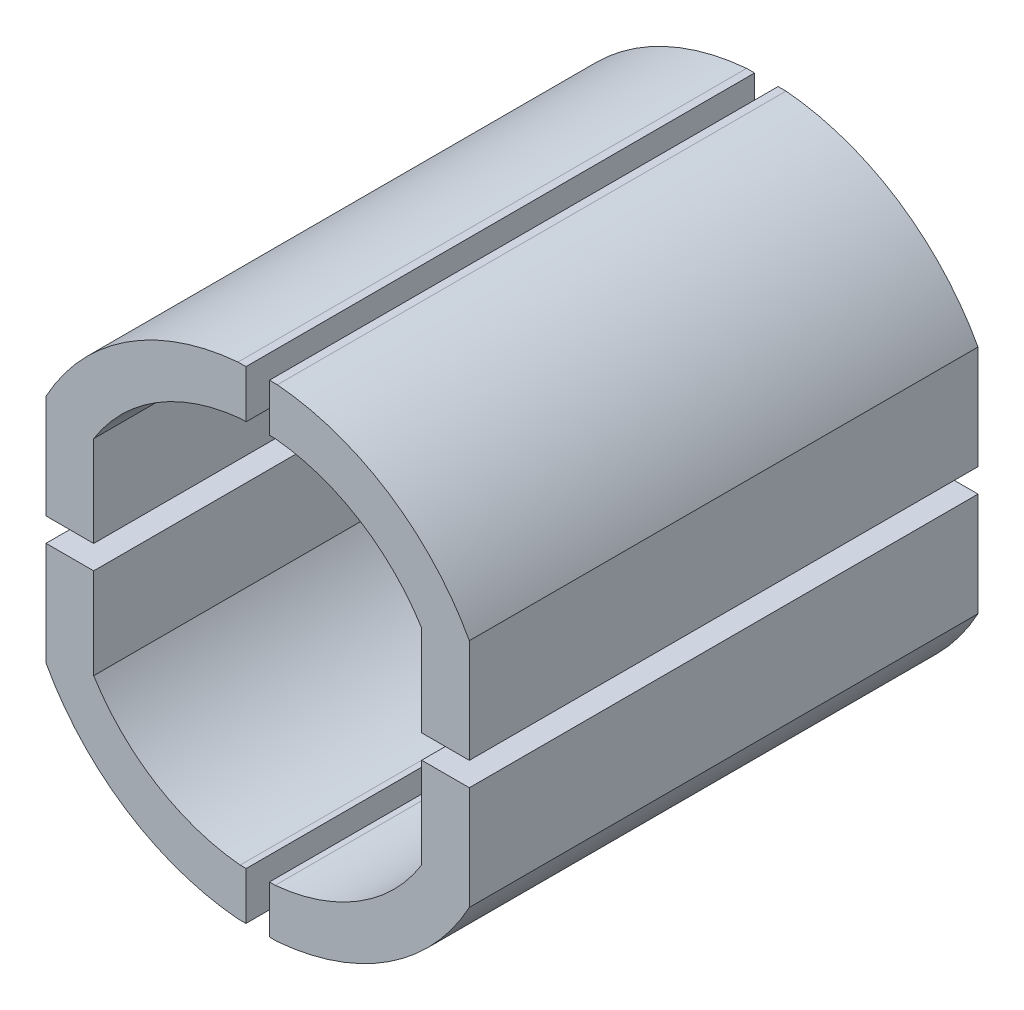
from build123d import *

# Parameters (mm, degrees)
BOSS_EXTRUDE1_DEPTH   = 32
BOSS_EXTRUDE1_2_DEPTH = 32
BOSS_EXTRUDE1_3_DEPTH = 32
BOSS_EXTRUDE1_4_DEPTH = 32


with BuildPart() as part:
    # Sketch1 → Boss-Extrude1 (new body)
    with BuildSketch(Plane.XY):
        with BuildLine():
            Line((11.055504192, 15.915227729), (11.055504192, 21.627656226))
            ThreePointArc((11.055504192, 21.627656226), (7.11644699, 25.56014018), (1.842224397, 27.338672642))
            Line((1.842224397, 27.338672642), (1.478906991, 27.338672642))
            Line((1.478906991, 27.338672642), (1.478906991, 30.338672642))
            Line((1.478906991, 30.338672642), (1.977816066, 30.338672642))
            ThreePointArc((1.977816066, 30.338672642), (9.01290626, 27.908773043), (14.055504192, 22.43436785))
            Line((14.055504192, 22.43436785), (14.055504192, 15.915227729))
            Line((14.055504192, 15.915227729), (11.055504192, 15.915227729))
        make_face()
    extrude(amount=BOSS_EXTRUDE1_DEPTH)


with BuildPart() as body_2:
    # Sketch1 → Boss-Extrude1 2 (new body)
    with BuildSketch(Plane.XY):
        with BuildLine():
            Line((0, 0), (0.012301558, 3))
            Line((0.012301558, 3), (-0.364412535, 3))
            ThreePointArc((-0.364412535, 3), (-5.638635128, 4.778532462), (-9.57769233, 8.711016416))
            Line((-9.57769233, 8.711016416), (-9.57769233, 14.423444914))
            Line((-9.57769233, 14.423444914), (-12.57769233, 14.423444914))
            Line((-12.57769233, 14.423444914), (-12.57769233, 7.904304792))
            ThreePointArc((-12.57769233, 7.904304792), (-7.535094399, 2.4298996), (-0.500004204, 0))
            Line((-0.500004204, 0), (0, 0))
        make_face()
    extrude(amount=BOSS_EXTRUDE1_2_DEPTH)


with BuildPart() as body_3:
    # Sketch1 → Boss-Extrude1 3 (new body)
    with BuildSketch(Plane.XY):
        with BuildLine():
            Line((0, 30.338672642), (0.012301765, 27.338672642))
            Line((0.012301765, 27.338672642), (-0.364412535, 27.338672642))
            ThreePointArc((-0.364412535, 27.338672642), (-5.638635128, 25.56014018), (-9.57769233, 21.627656226))
            Line((-9.57769233, 21.627656226), (-9.57769233, 15.915227729))
            Line((-9.57769233, 15.915227729), (-12.57769233, 15.915227729))
            Line((-12.57769233, 15.915227729), (-12.57769233, 22.43436785))
            ThreePointArc((-12.57769233, 22.43436785), (-7.535094399, 27.908773043), (-0.500004204, 30.338672642))
            Line((-0.500004204, 30.338672642), (0, 30.338672642))
        make_face()
    extrude(amount=BOSS_EXTRUDE1_3_DEPTH)


with BuildPart() as body_4:
    # Sketch1 → Boss-Extrude1 4 (new body)
    with BuildSketch(Plane.XY):
        with BuildLine():
            Line((14.055504192, 7.904304792), (14.055504192, 14.423444914))
            Line((14.055504192, 14.423444914), (11.055504192, 14.423444914))
            Line((11.055504192, 14.423444914), (11.055504192, 8.711016416))
            ThreePointArc((11.055504192, 8.711016416), (7.11644699, 4.778532462), (1.842224397, 3))
            Line((1.842224397, 3), (1.478906991, 3))
            Line((1.478906991, 3), (1.478906991, 0))
            Line((1.478906991, 0), (1.977816066, 0))
            ThreePointArc((1.977816066, 0), (9.01290626, 2.4298996), (14.055504192, 7.904304792))
        make_face()
    extrude(amount=BOSS_EXTRUDE1_4_DEPTH)


solid = Compound([part.part, body_2.part, body_3.part, body_4.part])
